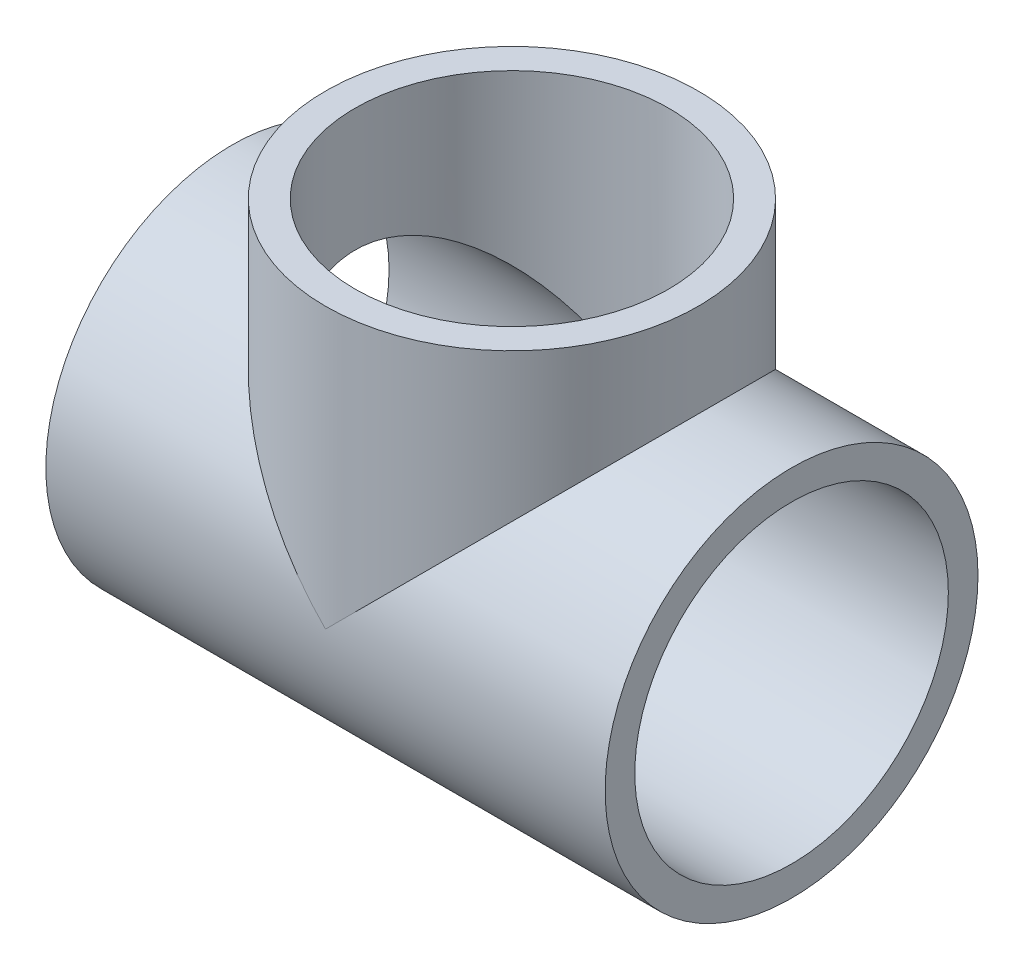
from build123d import *

# Parameters (mm, degrees)
SKETCH2_R           = 12.7
SKETCH2_R_2         = 10.6807
BOSS_EXTRUDE1_DEPTH = 19.05
BOSS_EXTRUDE2_REACH = 33.75
SKETCH5_R           = 12.7
CUT_EXTRUDE1_REACH  = 33.75
SKETCH6_R           = 10.6807


with BuildPart() as part:
    # Sketch2 → Boss-Extrude1 (new body, symmetric)
    with BuildSketch(Plane(origin=(0, 0, 0), x_dir=(0, 0, -1), z_dir=(1, 0, 0))):
        Circle(SKETCH2_R)
        Circle(SKETCH2_R_2, mode=Mode.SUBTRACT)
    extrude(amount=BOSS_EXTRUDE1_DEPTH, both=True)

    # Sketch5 → Boss-Extrude2 (add, up to next)
    with BuildSketch(Plane(origin=(0, 19.05, 0), x_dir=(1, 0, 0), z_dir=(0, 1, 0)), mode=Mode.PRIVATE) as boss_extrude2_sk1:
        Circle(SKETCH5_R)
    boss_extrude2_tool1 = extrude(boss_extrude2_sk1.sketch, amount=-BOSS_EXTRUDE2_REACH, mode=Mode.PRIVATE) - part.part
    add(boss_extrude2_tool1.solids().sort_by_distance((0, 19.05, 0))[0])

    # Sketch6 → Cut-Extrude1 (cut, up to next)
    with BuildSketch(Plane(origin=(0, 19.05, 0), x_dir=(1, 0, 0), z_dir=(0, 1, 0)), mode=Mode.PRIVATE) as cut_extrude1_sk1:
        Circle(SKETCH6_R)
    cut_extrude1_tool1 = extrude(cut_extrude1_sk1.sketch, amount=-CUT_EXTRUDE1_REACH, mode=Mode.PRIVATE) & part.part
    add(cut_extrude1_tool1.solids().sort_by_distance((0, 19.05, 0))[0], mode=Mode.SUBTRACT)


solid = part.part
